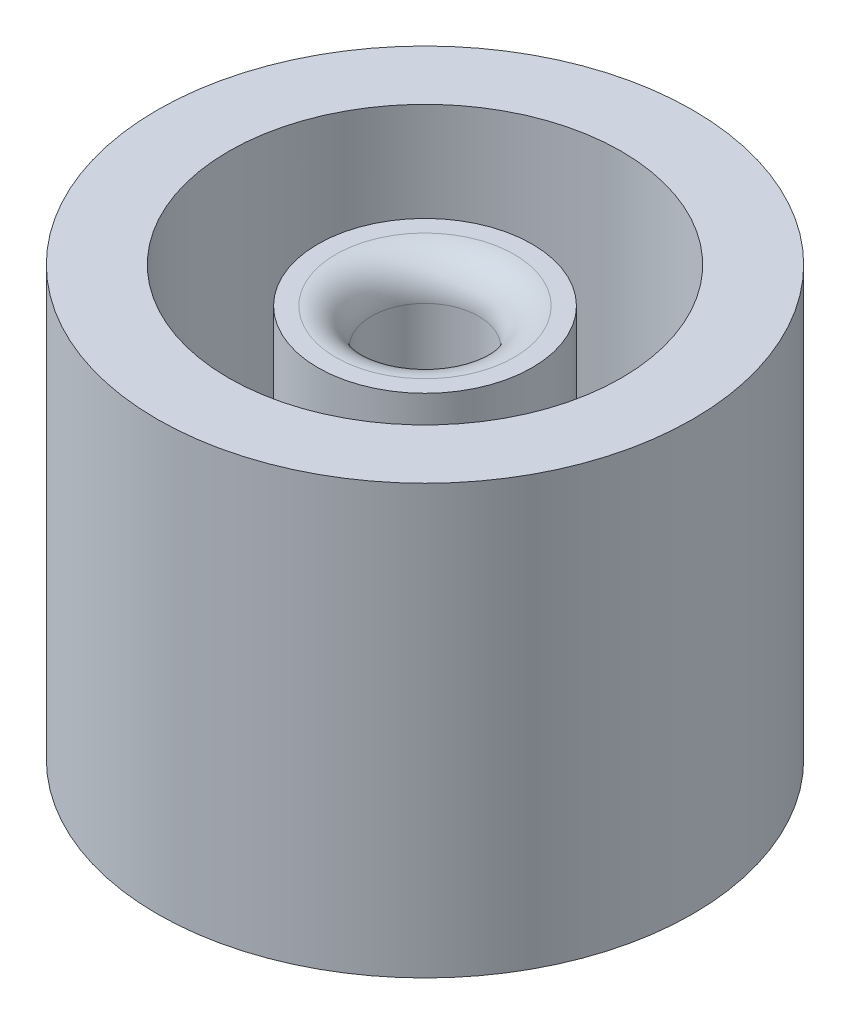
from build123d import *

# Parameters (mm, degrees)
SKETCH1_R           = 19.05
SKETCH1_R_2         = 13.97
BOSS_EXTRUDE1_DEPTH = 30.48
SKETCH2_R           = 13.97
BOSS_EXTRUDE2_DEPTH = 6.35
SKETCH7_R           = 5.08
CUT_EXTRUDE4_DEPTH  = 7.35
SKETCH9_R           = 7.62
SKETCH9_R_2         = 5.08
BOSS_EXTRUDE3_DEPTH = 13.97
SKETCH10_R          = 7.62
SKETCH10_R_2        = 3.81
BOSS_EXTRUDE4_DEPTH = 7.62
FILLET1_R           = 2.54


with BuildPart() as part:
    # Sketch1 → Boss-Extrude1 (new body)
    with BuildSketch(Plane(origin=(0, 0, 0), x_dir=(1, 0, 0), z_dir=(0, 1, 0))):
        Circle(SKETCH1_R)
        Circle(SKETCH1_R_2, mode=Mode.SUBTRACT)
    extrude(amount=BOSS_EXTRUDE1_DEPTH)

    # Sketch2 → Boss-Extrude2 (add)
    with BuildSketch(Plane.XZ):
        Circle(SKETCH2_R)
    extrude(amount=-BOSS_EXTRUDE2_DEPTH)

    # Sketch7 → Cut-Extrude4 (cut, through all)
    with BuildSketch(Plane(origin=(0, 6.35, 0), x_dir=(1, 0, 0), z_dir=(0, 1, 0))):
        Circle(SKETCH7_R)
    extrude(amount=-CUT_EXTRUDE4_DEPTH, mode=Mode.SUBTRACT)

    # Sketch9 → Boss-Extrude3 (add)
    with BuildSketch(Plane(origin=(0, 6.35, 0), x_dir=(1, 0, 0), z_dir=(0, 1, 0))):
        Circle(SKETCH9_R)
        Circle(SKETCH9_R_2, mode=Mode.SUBTRACT)
    extrude(amount=BOSS_EXTRUDE3_DEPTH)

    # Sketch10 → Boss-Extrude4 (add)
    with BuildSketch(Plane(origin=(0, 20.32, 0), x_dir=(1, 0, 0), z_dir=(0, 1, 0))):
        Circle(SKETCH10_R)
        Circle(SKETCH10_R_2, mode=Mode.SUBTRACT)
    extrude(amount=BOSS_EXTRUDE4_DEPTH)

    # Fillet1
    fillet1_edges = [part.edges().sort_by_distance(p)[0] for p in [
        (-3.81, 27.94, 0),
    ]]
    fillet(fillet1_edges, radius=FILLET1_R)


solid = part.part
